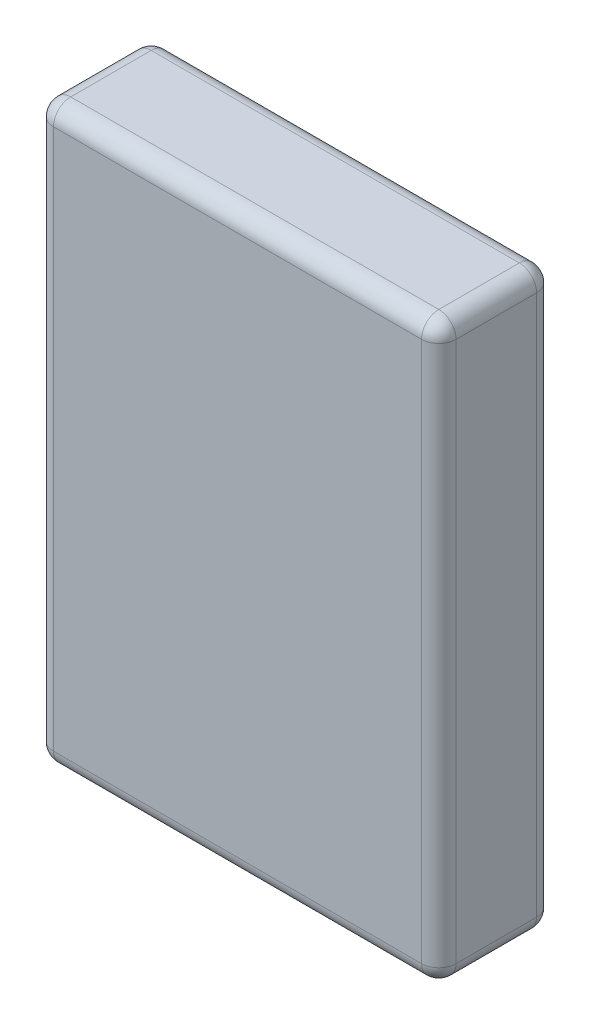
from build123d import *

# Parameters (mm, degrees)
SKETCH1_W           = 70
SKETCH1_H           = 100
BOSS_EXTRUDE1_DEPTH = 20
FILLET1_R           = 3


with BuildPart() as part:
    # Sketch1 → Boss-Extrude1 (new body)
    with BuildSketch(Plane.XY):
        with Locations((35, 50)):
            Rectangle(SKETCH1_W, SKETCH1_H)
    extrude(amount=BOSS_EXTRUDE1_DEPTH)

    # Fillet1
    fillet1_edges = [part.edges().sort_by_distance(p)[0] for p in [
        (70, 50, 20),
        (35, 100, 20),
        (0, 50, 20),
        (35, 100, 0),
        (70, 50, 0),
        (35, 0, 0),
        (0, 50, 0),
        (35, 0, 20),
        (0, 100, 10),
        (70, 100, 10),
        (70, 0, 10),
        (0, 0, 10),
    ]]
    fillet(fillet1_edges, radius=FILLET1_R)


solid = part.part
